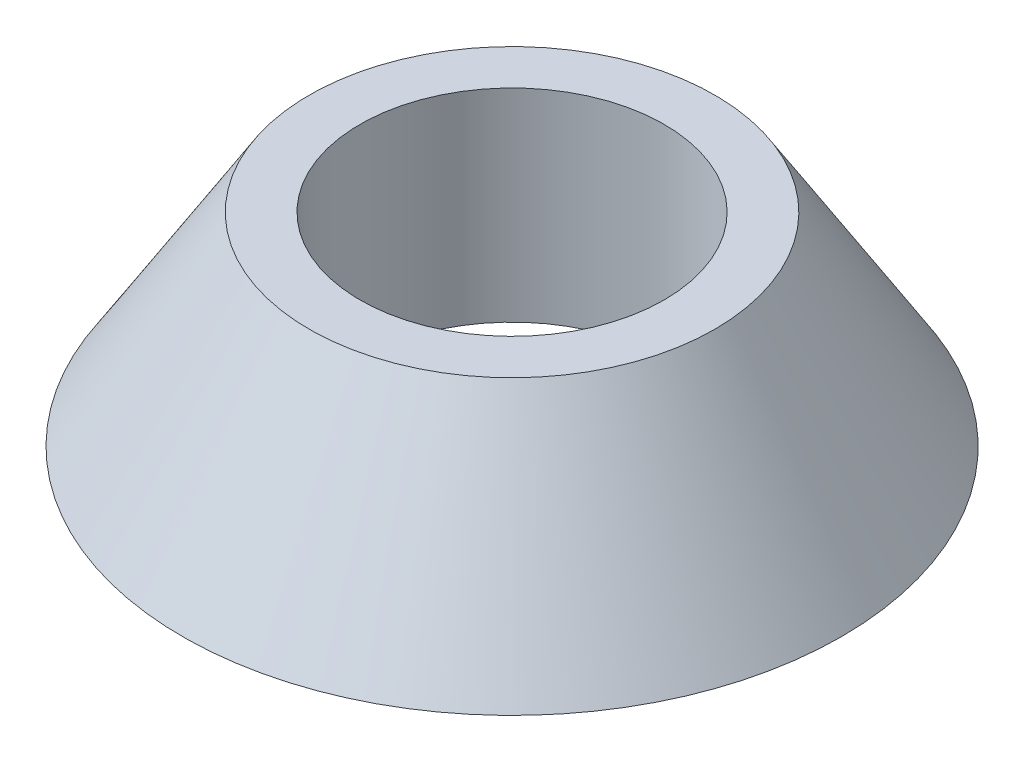
from build123d import *


with BuildPart() as part:
    # Szkic1 → Obrót1 (revolve)
    with BuildSketch(Plane.XY):
        Polygon((3, 0), (3, 4), (4, 4), (6.5, 0), align=None)
    revolve(axis=Axis((0, 0, 0), (0, 1, 0)))


solid = part.part
